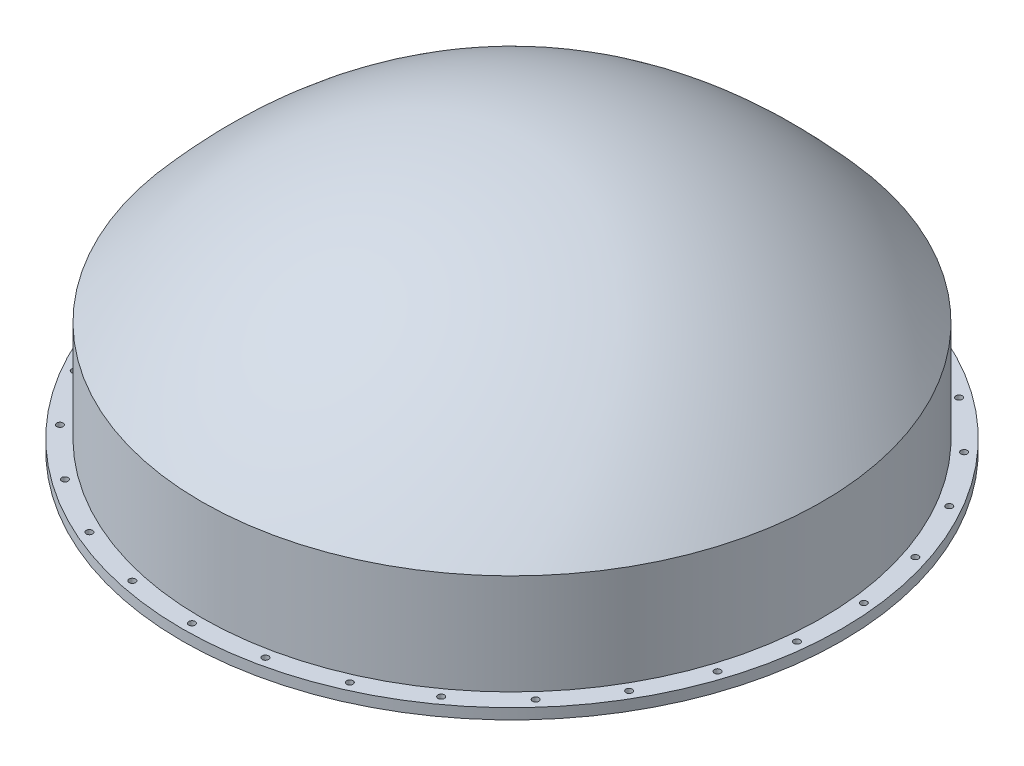
from build123d import *

# Parameters (mm, degrees)
SKETCH2_R          = 22
CUT_EXTRUDE1_DEPTH = 73


with BuildPart() as part:
    # Sketch1 → Revolve1 (revolve)
    with BuildSketch(Plane(origin=(0, 0, 0), x_dir=(0, 0, -1), z_dir=(1, 0, 0))):
        with BuildLine():
            Line((-2081.13, 0), (-2081.13, -744.115))
            Line((-2081.13, -744.115), (-2262.02, -744.115))
            Line((-2262.02, -744.115), (-2262.02, -671.115))
            Line((-2262.02, -671.115), (-2130.02, -671.115))
            Line((-2130.02, -671.115), (-2130.02, 18.415372076))
            add(Edge.make_bspline(
                [(0, 1093.3), (-111.945674729, 1093.301964169), (-331.549711188, 1074.332200736), (-582.656555599, 1030.041438516), (-861.641512528, 945.67320197), (-1132.404227913, 827.653731699), (-1394.784318246, 676.14164624), (-1616.963153693, 514.420185996), (-1771.693030405, 383.360606327), (-1878.156335698, 284.381935555), (-1953.214672008, 209.812058966), (-2005.296009742, 155.808339202), (-2042.251263633, 116.267998019), (-2068.005468178, 88.138958469), (-2086.339931254, 67.805498907), (-2099.145942337, 53.458924443), (-2108.276321328, 43.152645167), (-2114.666386739, 35.903586551), (-2119.208174357, 30.731122283), (-2125.509674702, 23.552924448), (-2130.02, 18.415372076)],
                knots=[0, 0, 0, 0.094371124, 0.188742248, 0.314570414, 0.440398579, 0.566226745, 0.69205491, 0.786426034, 0.849340117, 0.896525679, 0.92798272, 0.951575501, 0.967304022, 0.979100413, 0.986964673, 0.992862868, 0.996794998, 0.999744096, 1.001710161, 1.006625324, 1.006625324, 1.006625324], degree=2))
            Line((0, 1093.3), (0, 1044.41))
            add(Edge.make_bspline(
                [(0, 1044.41), (-1164.248075476, 1044.41), (-2081.13, 0)],
                knots=[0, 0, 0, 1, 1, 1], degree=2))
        make_face()
    revolve(axis=Axis((0, 1093.3, 0), (0, -1, 0)))

    # Sketch2 → Cut-Extrude1 (cut)
    with BuildSketch(Plane(origin=(0, -671.115, 0), x_dir=(1, 0, 0), z_dir=(0, 1, 0))):
        with Locations((0, 2196.0235)):
            Circle(SKETCH2_R)
        with Locations((456.578958961, 2148.03511768)):
            Circle(SKETCH2_R)
        with Locations((893.203226506, 2006.167293301)):
            Circle(SKETCH2_R)
        with Locations((1290.790226988, 1776.620331547)):
            Circle(SKETCH2_R)
        with Locations((1631.963500652, 1469.426536133)):
            Circle(SKETCH2_R)
        with Locations((1901.812138308, 1098.01175)):
            Circle(SKETCH2_R)
        with Locations((2088.542459612, 678.608581547)):
            Circle(SKETCH2_R)
        with Locations((2183.993453493, 229.546961755)):
            Circle(SKETCH2_R)
        with Locations((2183.993453493, -229.546961755)):
            Circle(SKETCH2_R)
        with Locations((2088.542459612, -678.608581547)):
            Circle(SKETCH2_R)
        with Locations((1901.812138308, -1098.01175)):
            Circle(SKETCH2_R)
        with Locations((1631.963500652, -1469.426536133)):
            Circle(SKETCH2_R)
        with Locations((1290.790226988, -1776.620331547)):
            Circle(SKETCH2_R)
        with Locations((893.203226506, -2006.167293301)):
            Circle(SKETCH2_R)
        with Locations((456.578958961, -2148.03511768)):
            Circle(SKETCH2_R)
        with Locations((0, -2196.0235)):
            Circle(SKETCH2_R)
        with Locations((-456.57895896, -2148.03511768)):
            Circle(SKETCH2_R)
        with Locations((-893.203226505, -2006.167293301)):
            Circle(SKETCH2_R)
        with Locations((-1290.790226988, -1776.620331547)):
            Circle(SKETCH2_R)
        with Locations((-1631.963500652, -1469.426536133)):
            Circle(SKETCH2_R)
        with Locations((-1901.812138308, -1098.01175)):
            Circle(SKETCH2_R)
        with Locations((-2088.542459612, -678.608581547)):
            Circle(SKETCH2_R)
        with Locations((-2183.993453493, -229.546961755)):
            Circle(SKETCH2_R)
        with Locations((-2183.993453493, 229.546961755)):
            Circle(SKETCH2_R)
        with Locations((-2088.542459612, 678.608581547)):
            Circle(SKETCH2_R)
        with Locations((-1901.812138308, 1098.01175)):
            Circle(SKETCH2_R)
        with Locations((-1631.963500652, 1469.426536133)):
            Circle(SKETCH2_R)
        with Locations((-1290.790226988, 1776.620331547)):
            Circle(SKETCH2_R)
        with Locations((-893.203226506, 2006.167293301)):
            Circle(SKETCH2_R)
        with Locations((-456.578958961, 2148.03511768)):
            Circle(SKETCH2_R)
    extrude(amount=-CUT_EXTRUDE1_DEPTH, mode=Mode.SUBTRACT)


solid = part.part
